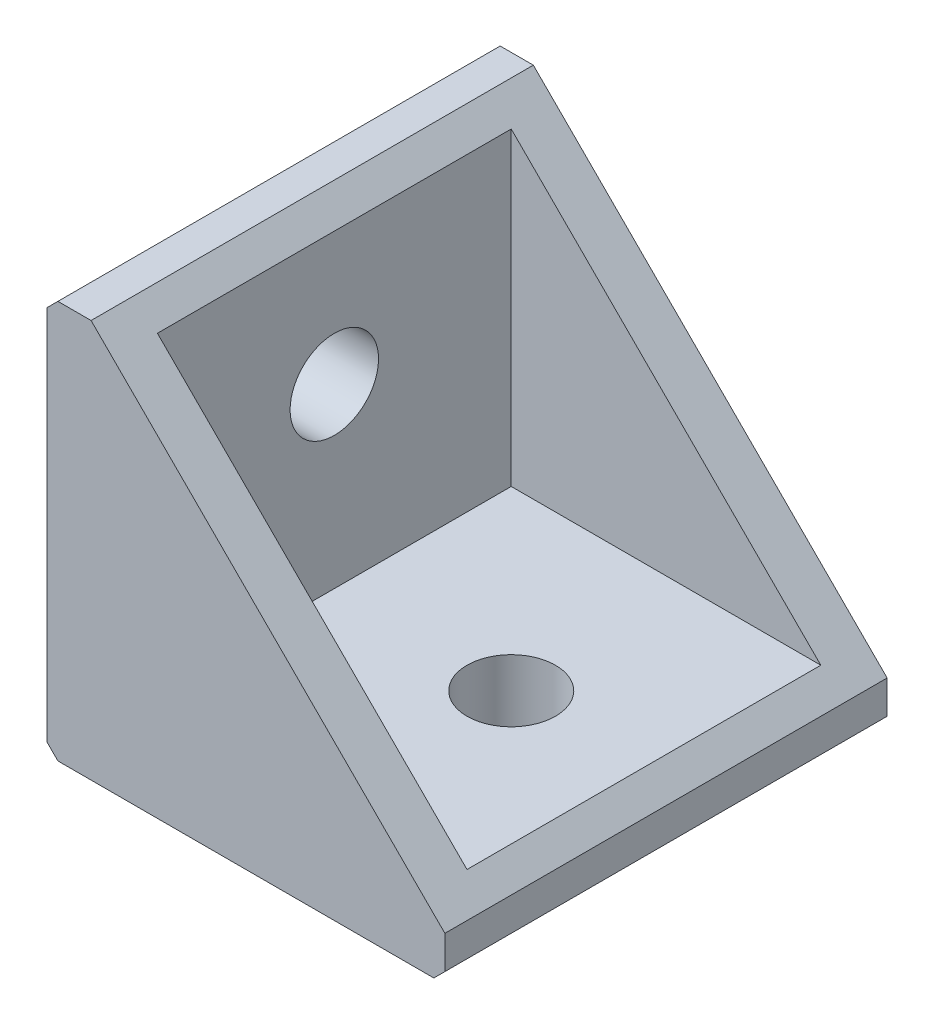
from build123d import *

# Parameters (mm, degrees)
ESQUISSE1_W             = 18
ESQUISSE1_H             = 18
BOSS_EXTRU_1_DEPTH      = 20
ENL_V_MAT_EXTRU_1_DEPTH = 20
ENL_V_START             = -2
ENL_V_MAT_EXTRU_2_DEPTH = 16
CHANFREIN1_SIZE         = 0.5
ESQUISSE4_R             = 2
ENL_V_MAT_EXTRU_3_DEPTH = 4
ESQUISSE5_R             = 2
ENL_V_MAT_EXTRU_4_DEPTH = 4


with BuildPart() as part:
    # Esquisse1 → Boss.-Extru.1 (new body)
    with BuildSketch(Plane.XY):
        with Locations((9, 9)):
            Rectangle(ESQUISSE1_W, ESQUISSE1_H)
    extrude(amount=BOSS_EXTRU_1_DEPTH)

    # Esquisse2 → Enlèv. mat.-Extru.1 (cut)
    with BuildSketch(Plane.XY.offset(20)):
        Polygon((18, 18), (2, 18), (18, 2), align=None)
    extrude(amount=-ENL_V_MAT_EXTRU_1_DEPTH, mode=Mode.SUBTRACT)

    # Esquisse3 → Enlèv. mat.-Extru.2 (cut)
    with BuildSketch(Plane.XY.offset(20).offset(ENL_V_START)):
        Polygon((3, 17), (3, 3), (17, 3), align=None)
    extrude(amount=-ENL_V_MAT_EXTRU_2_DEPTH, mode=Mode.SUBTRACT)

    # Chanfrein1
    chanfrein1_edges = [part.edges().sort_by_distance(p)[0] for p in [
        (0, 18, 10),
        (18, 0, 10),
        (0, 0, 10),
    ]]
    chamfer(chanfrein1_edges, length=CHANFREIN1_SIZE)

    # Esquisse4 → Enlèv. mat.-Extru.3 (cut, through all)
    with BuildSketch(Plane(origin=(3, 0, 0), x_dir=(0, 0, -1), z_dir=(1, 0, 0))):
        with Locations((-10, 11)):
            Circle(ESQUISSE4_R)
    extrude(amount=-ENL_V_MAT_EXTRU_3_DEPTH, mode=Mode.SUBTRACT)

    # Esquisse5 → Enlèv. mat.-Extru.4 (cut, through all)
    with BuildSketch(Plane(origin=(0, 3, 0), x_dir=(1, 0, 0), z_dir=(0, 1, 0))):
        with Locations((11, -10)):
            Circle(ESQUISSE5_R)
    extrude(amount=-ENL_V_MAT_EXTRU_4_DEPTH, mode=Mode.SUBTRACT)


solid = part.part
